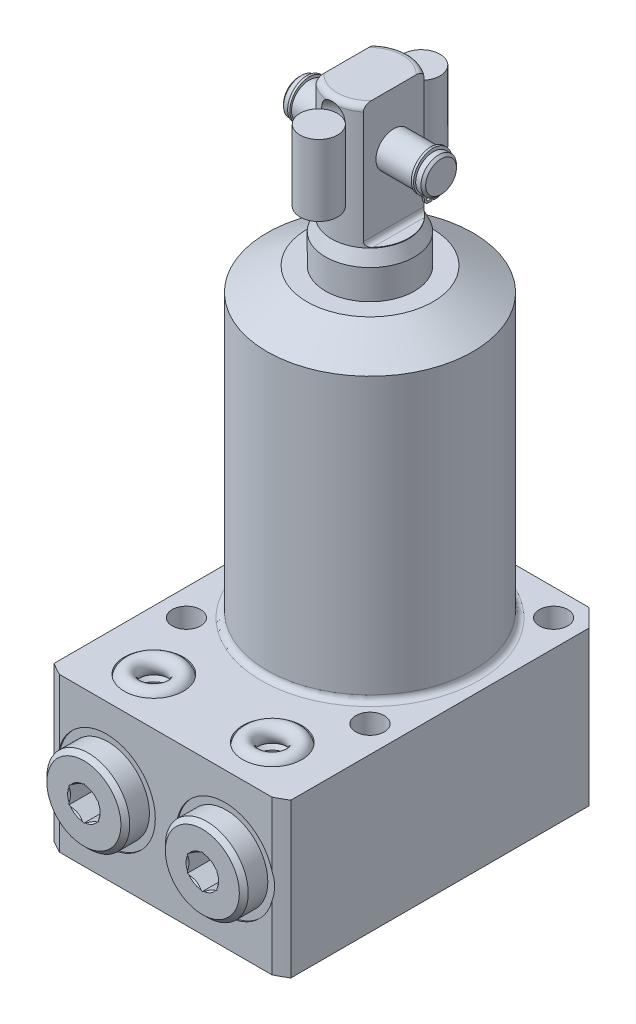
from build123d import *

# Parameters (mm, degrees)
FLATS_DEPTH            = 50
SKETCH23_R             = 0.33
RETAINING_RING_DEPTH   = 0.381
SKETCH24_W             = 3.175
SKETCH24_H             = 12
SKETCH7_OUTSIDE_W      = 110.274
SKETCH7_OUTSIDE_H      = 110.274
SKETCH7_OUTSIDE_W_2    = 40
SKETCH7_OUTSIDE_H_2    = 54.5
FLANGE_SIDES_DEPTH     = 27
SKETCH8_R              = 2.4
MOUNTING_HOLES_DEPTH   = 106.5000001
MOUNTING_PATTERN_COUNT = 4
FLANGE_CHAMFER_SIZE    = 3
BODY_FILLET_R          = 1
BSPP_PLUG_HEX_DEPTH    = 4.06
SKETCH16_R             = 1.5


with BuildPart() as part:
    # Sketch1 → PLUNGER (revolve)
    with BuildSketch(Plane.XY, mode=Mode.PRIVATE) as plunger_sk:
        with BuildLine():
            Line((7.5, 0), (7.5, 56.5))
            Line((7.5, 56.5), (6.5, 58.644506921))
            Line((6.5, 58.644506921), (6.5, 78.5))
            ThreePointArc((6.5, 78.5), (6.207106781, 79.207106781), (5.5, 79.5))
            Line((5.5, 79.5), (0, 79.5))
            Line((0, 79.5), (0, 0))
            Line((0, 0), (7.5, 0))
        make_face()
    revolve(plunger_sk.sketch.rotate(Axis((0, -3.075, 0), (0, 1, 0)), 90), axis=Axis((0, -3.075, 0), (0, 1, 0)))  # turned: the seam where the file's is

    # Sketch17 → FLATS (cut, symmetric)
    with BuildSketch(Plane.XY):
        with BuildLine():
            Line((4, 79.5), (6.5, 79.5))
            Line((6.5, 79.5), (6.5, 58.75))
            Line((6.5, 58.75), (4.8, 58.75))
            ThreePointArc((4.8, 58.75), (4.234314575, 58.984314575), (4, 59.55))
            Line((4, 59.55), (4, 79.5))
        make_face()
        with BuildLine():
            Line((-6.5, 79.5), (-6.5, 58.75))
            Line((-6.5, 58.75), (-4.8, 58.75))
            ThreePointArc((-4.8, 58.75), (-4.234314575, 58.984314575), (-4, 59.55))
            Line((-4, 59.55), (-4, 79.5))
            Line((-4, 79.5), (-6.5, 79.5))
        make_face()
    extrude(amount=FLATS_DEPTH, both=True, mode=Mode.SUBTRACT)

    # Sketch22 → PIVOT_PIN (revolve)
    with BuildSketch(Plane.XY, mode=Mode.PRIVATE) as pivot_pin_sk:
        Polygon((-12, 73.1), (-11.6, 73.5), (-10.71, 73.5), (-10.71, 73.32), (-10.25, 73.32), (-10.25, 73.5), (10.25, 73.5), (10.25, 73.32), (10.71, 73.32), (10.71, 73.5), (11.6, 73.5), (12, 73.1), (12, 70.5), (-12, 70.5), align=None)
    revolve(pivot_pin_sk.sketch.rotate(Axis((-11.568872367, 70.5, 0), (1, 0, 0)), 90), axis=Axis((-11.568872367, 70.5, 0), (1, 0, 0)))  # turned: the seam where the file's is

    # Sketch23 → RETAINING_RING (add)
    with BuildSketch(Plane(origin=(10.25, 0, 0), x_dir=(0, 0, -1), z_dir=(1, 0, 0))):
        with BuildLine():
            Line((-0.1775, 66.355776487), (-0.76, 66.355776487))
            ThreePointArc((-0.76, 66.355776487), (-1.226690476, 66.549086011), (-1.42, 67.015776487))
            ThreePointArc((-1.42, 67.015776487), (-1.538610281, 67.505723563), (-1.868175115, 67.887172846))
            ThreePointArc((-1.868175115, 67.887172846), (-3.129494684, 71.611416248), (0, 73.992))
            ThreePointArc((0, 73.992), (3.129494684, 71.611416248), (1.868175115, 67.887172846))
            ThreePointArc((1.868175115, 67.887172846), (1.538610281, 67.505723563), (1.42, 67.015776487))
            ThreePointArc((1.42, 67.015776487), (1.226690476, 66.549086011), (0.76, 66.355776487))
            Line((0.76, 66.355776487), (0.1775, 66.355776487))
            Line((0.1775, 66.355776487), (0.1775, 67.775776487))
            ThreePointArc((0.1775, 67.775776487), (0, 73.23), (-0.1775, 67.775776487))
            Line((-0.1775, 67.775776487), (-0.1775, 66.355776487))
        make_face()
        with Locations((-0.76, 67.015776487)):
            Circle(SKETCH23_R, mode=Mode.SUBTRACT)
        with Locations(Location((0.76, 67.015776487, 0), (0, 0, 180))):  # turned: the seam where the file's is
            Circle(SKETCH23_R, mode=Mode.SUBTRACT)
    retaining_ring = extrude(amount=RETAINING_RING_DEPTH)

    # RETAINING_RING-OPP: RETAINING_RING across plane
    add(retaining_ring.mirror(Plane.ZY))

    # Sketch20 → SPRING_SLOT (revolve, cut)
    with BuildSketch(Plane.ZY):
        with BuildLine():
            Line((5.5, 76.5), (5.5, 64.5))
            ThreePointArc((5.5, 64.5), (6.42993597, 62.25493597), (8.675, 61.325))
            Line((8.675, 61.325), (8.675, 79.675))
            ThreePointArc((8.675, 79.675), (6.42993597, 78.74506403), (5.5, 76.5))
        make_face()
    spring_slot = revolve(axis=Axis((0, 86.547956129, 8.675), (0, -1, 0)), mode=Mode.SUBTRACT)

    # SPRING_SLOT_OPP: SPRING_SLOT across plane
    add(spring_slot.mirror(Plane.XY), mode=Mode.SUBTRACT)

    # Sketch24 → SPRING (revolve)
    with BuildSketch(Plane.ZY):
        with Locations((-7.0575, 70.5)):
            Rectangle(SKETCH24_W, SKETCH24_H)
    spring = revolve(axis=Axis((0, 84.567834264, -8.645), (0, -1, 0)))

    # SPRING_OPP: SPRING across plane
    add(spring.mirror(Plane.XY))

    # Sketch6 → BODY_REVOLVE (revolve)
    with BuildSketch(Plane.XY, mode=Mode.PRIVATE) as body_revolve_sk:
        Polygon((0, 51.5), (10.625, 51.5), (17.385, 47.59711218), (17.385, 0), (38.895, 0), (38.895, -26), (0, -26), align=None)
    revolve(body_revolve_sk.sketch.rotate(Axis((0, -26, 0), (0, 1, 0)), 90), axis=Axis((0, -26, 0), (0, 1, 0)))  # turned: the seam where the file's is

    # Sketch7 outside → FLANGE_SIDES (cut, through all)
    with BuildSketch(Plane(origin=(0, 0, 0), x_dir=(-1, 0, 0), z_dir=(0, 1, 0))):
        Rectangle(SKETCH7_OUTSIDE_W, SKETCH7_OUTSIDE_H)
        with Locations((0, 7.25)):
            Rectangle(SKETCH7_OUTSIDE_W_2, SKETCH7_OUTSIDE_H_2, mode=Mode.SUBTRACT)
    extrude(amount=-FLANGE_SIDES_DEPTH, mode=Mode.SUBTRACT)

    # Sketch8 → MOUNTING HOLES (cut, through all)
    with BuildSketch(Plane.XZ.offset(26)):
        with Locations(Location((-15.5, 15.5, 0), (0, 0, 270))):  # turned: the seam where the file's is
            Circle(SKETCH8_R)
    mounting_holes = extrude(amount=-MOUNTING_HOLES_DEPTH, mode=Mode.SUBTRACT)

    # MOUNTING_PATTERN: MOUNTING HOLES ×4 about axis
    mounting_pattern_axis = Axis((0, 0, 0), (0, 1, 0))
    for i in range(1, MOUNTING_PATTERN_COUNT):
        add(mounting_holes.rotate(mounting_pattern_axis, i * 360 / MOUNTING_PATTERN_COUNT), mode=Mode.SUBTRACT)

    # FLANGE_CHAMFER
    flange_chamfer_edges = [part.edges().sort_by_distance(p)[0] for p in [
        (-20, -13, -20),
        (20, -13, -20),
    ]]
    chamfer(flange_chamfer_edges, length=FLANGE_CHAMFER_SIZE)

    # BODY_FILLET
    body_fillet_edges = [part.edges().sort_by_distance(p)[0] for p in [
        (0, 0, 17.385),
    ]]
    fillet(body_fillet_edges, radius=BODY_FILLET_R)

    # Sketch11 → PORT SPOT FACE (revolve, cut)
    with BuildSketch(Plane.XZ.offset(13), mode=Mode.PRIVATE) as port_spot_face_sk:
        Polygon((-18.25, 34.5), (-18.25, 34.25), (-15, 34.25), (-14.42, 33.67), (-14.42, 19.09), (-10, 19.09), (-10, 34.5), align=None)
    port_spot_face = revolve(port_spot_face_sk.sketch.rotate(Axis((-10, -13, 42.971570338), (0, 0, -1)), 180), axis=Axis((-10, -13, 42.971570338), (0, 0, -1)), mode=Mode.SUBTRACT)  # turned: the seam where the file's is

    # Sketch13 → BOTTOM_MANIFOLD_PORT (revolve, cut)
    with BuildSketch(Plane.XY.offset(26.5)):
        Polygon((-12.5, -14), (-12.5, -23.125), (-13.125, -23.75), (-15, -23.75), (-15, -26), (-10, -26), (-10, -14), align=None)
    bottom_manifold_port = revolve(axis=Axis((-10, 15.209907045, 26.5), (0, -1, 0)), mode=Mode.SUBTRACT)

    # Sketch14 → BSPP_PLUGHEAD (revolve)
    with BuildSketch(Plane.XZ.offset(13)):
        Polygon((-12.75, 38.31), (-16.25, 38.31), (-17, 37.56), (-17, 34.25), (-14.125, 34.25), (-14.125, 31.80784845), (-10, 31.80784845), (-10, 31.80884845), (-12.5, 33.310999998), (-12.5, 38.06), align=None)
    bspp_plughead = revolve(axis=Axis((-10, -13, 32.588064048), (0, 0, 1)))

    # Sketch15 → BSPP_PLUG_HEX (cut)
    with BuildSketch(Plane.XY.offset(38.31)):
        Polygon((-7.5, -14.443375673), (-7.5, -11.556624327), (-10, -10.113248654), (-12.5, -11.556624327), (-12.5, -14.443375673), (-10, -15.886751346), align=None)
    bspp_plug_hex = extrude(amount=-BSPP_PLUG_HEX_DEPTH, mode=Mode.SUBTRACT)

    # MANIFOLD_TOP_MIRROR: BOTTOM_MANIFOLD_PORT across plane
    add(bottom_manifold_port.mirror(Plane(origin=(0, -13, 0), x_dir=(0, 0, 1), z_dir=(0, -1, 0))), mode=Mode.SUBTRACT)

    # BSPP-MANIFOLD_MIRROR: PORT SPOT FACE, BOTTOM_MANIFOLD_PORT, BSPP_PLUGHEAD, BSPP_PLUG_HEX across plane
    add(port_spot_face.mirror(Plane(origin=(0, 0, 0), x_dir=(0, 0, 1), z_dir=(1, 0, 0))), mode=Mode.SUBTRACT)
    add(bottom_manifold_port.mirror(Plane(origin=(0, 0, 0), x_dir=(0, 0, 1), z_dir=(1, 0, 0))), mode=Mode.SUBTRACT)
    add(bspp_plughead.mirror(Plane(origin=(0, 0, 0), x_dir=(0, 0, 1), z_dir=(1, 0, 0))))
    add(bspp_plug_hex.mirror(Plane(origin=(0, 0, 0), x_dir=(0, 0, 1), z_dir=(1, 0, 0))), mode=Mode.SUBTRACT)

    # BSPP-MANIFOLD_MIRROR copy 1 sketch → BSPP-MANIFOLD_MIRROR copy 1 (revolve, cut)
    with BuildSketch(Plane(origin=(0, -26, 26.5), x_dir=(-1, 0, 0), z_dir=(0, 0, 1))):
        Polygon((-12.5, -14), (-12.5, -23.125), (-13.125, -23.75), (-15, -23.75), (-15, -26), (-10, -26), (-10, -14), align=None)
    revolve(axis=Axis((10, -41.209907045, 26.5), (0, 1, 0)), mode=Mode.SUBTRACT)


with BuildPart() as body_2:
    # Sketch16 → MANIFOLD_O-RING (revolve)
    with BuildSketch(Plane.XY.offset(26.5)):
        with Locations((-13.5, -25.25)):
            Circle(SKETCH16_R)
    revolve(axis=Axis((-10, 9.321927472, 26.5), (0, -1, 0)))


with BuildPart() as body_3:
    # MANIFOLD_O-RING_MIRROR: mirrored copy
    add(body_2.part.mirror(Plane(origin=(0, 0, 0), x_dir=(0, 0, 1), z_dir=(1, 0, 0))))


with BuildPart() as body_4:
    # MANIFOLD_O-RING_MIRROR_TOP: mirrored copy
    add(body_2.part.mirror(Plane(origin=(0, -13, 0), x_dir=(0, 0, 1), z_dir=(0, -1, 0))))


with BuildPart() as body_5:
    # MANIFOLD_O-RING_MIRROR_TOP 2: mirrored copy
    add(body_3.part.mirror(Plane(origin=(0, -13, 0), x_dir=(0, 0, 1), z_dir=(0, -1, 0))))


solid = Compound([part.part, body_2.part, body_3.part, body_4.part, body_5.part])
